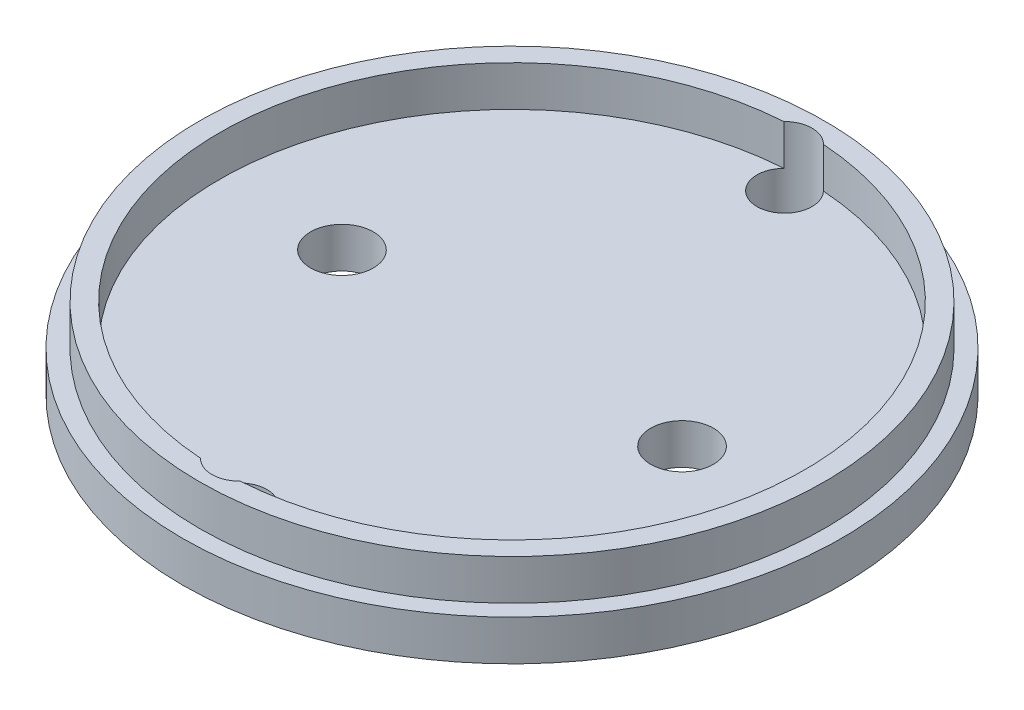
from build123d import *

# Parameters (mm, degrees)
SKETCH1_R               = 38.6
SKETCH1_R_2             = 36.1
BOSS_EXTRUDE1_DEPTH     = 5
SKETCH1_4_R             = 40.7
BOSS_EXTRUDE2_DEPTH     = 5
CUT_EXTRUDE1_DEPTH      = 59.420715504
CUT_EXTRUDE1_DEPTH_BACK = 59.420715504
SKETCH4_R               = 3.875
SKETCH4_R_2             = 3.4


with BuildPart() as part:
    # Sketch1 → Boss-Extrude1 (new body)
    with BuildSketch(Plane(origin=(0, 0, 0), x_dir=(1, 0, 0), z_dir=(0, 1, 0))):
        Circle(SKETCH1_R)
        Circle(SKETCH1_R_2, mode=Mode.SUBTRACT)
    extrude(amount=BOSS_EXTRUDE1_DEPTH)

    # Sketch1_4 → Boss-Extrude2 (add)
    with BuildSketch(Plane(origin=(0, 0, 0), x_dir=(1, 0, 0), z_dir=(0, 1, 0))):
        Circle(SKETCH1_4_R)
    extrude(amount=-BOSS_EXTRUDE2_DEPTH)

    # Sketch4 → Cut-Extrude1 (cut, two sides: drawn at the far end of the back side and taken through both)
    with BuildSketch(Plane.XZ.offset(5).offset(-CUT_EXTRUDE1_DEPTH_BACK)):
        with Locations((-21, 0)):
            Circle(SKETCH4_R)
        with Locations((21, 0)):
            Circle(SKETCH4_R)
        with Locations((0, 33.655)):
            Circle(SKETCH4_R_2)
        with Locations((0, -33.655)):
            Circle(SKETCH4_R_2)
    extrude(amount=CUT_EXTRUDE1_DEPTH + CUT_EXTRUDE1_DEPTH_BACK, mode=Mode.SUBTRACT)


solid = part.part
